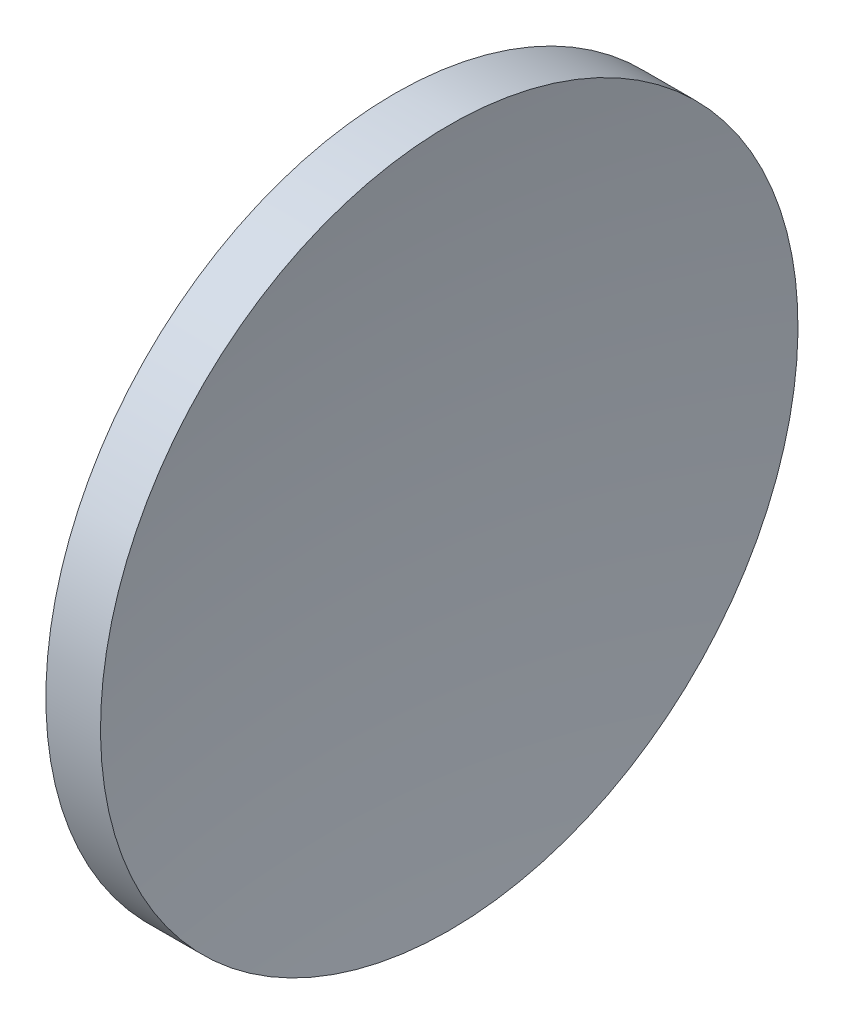
from build123d import *


with BuildPart() as part:
    # 草图1 → 旋转1 (revolve)
    with BuildSketch(Plane.XY, mode=Mode.PRIVATE) as revolve_1_sk:
        with BuildLine():
            Line((126.974048666, 84.241840471), (129.954173926, 84.241840471))
            ThreePointArc((129.954173926, 84.241840471), (128.830688998, 74.758812023), (128.455421316, 65.216840471))
            Line((128.455421316, 65.216840471), (122.855421316, 65.216840471))
            ThreePointArc((122.855421316, 65.216840471), (123.896867392, 74.94969355), (126.974048666, 84.241840471))
        make_face()
    revolve(revolve_1_sk.sketch.rotate(Axis((115.944491298, 65.216840471, 0), (1, 0, 0)), 180), axis=Axis((115.944491298, 65.216840471, 0), (1, 0, 0)))  # turned: the seam where the file's is


solid = part.part
